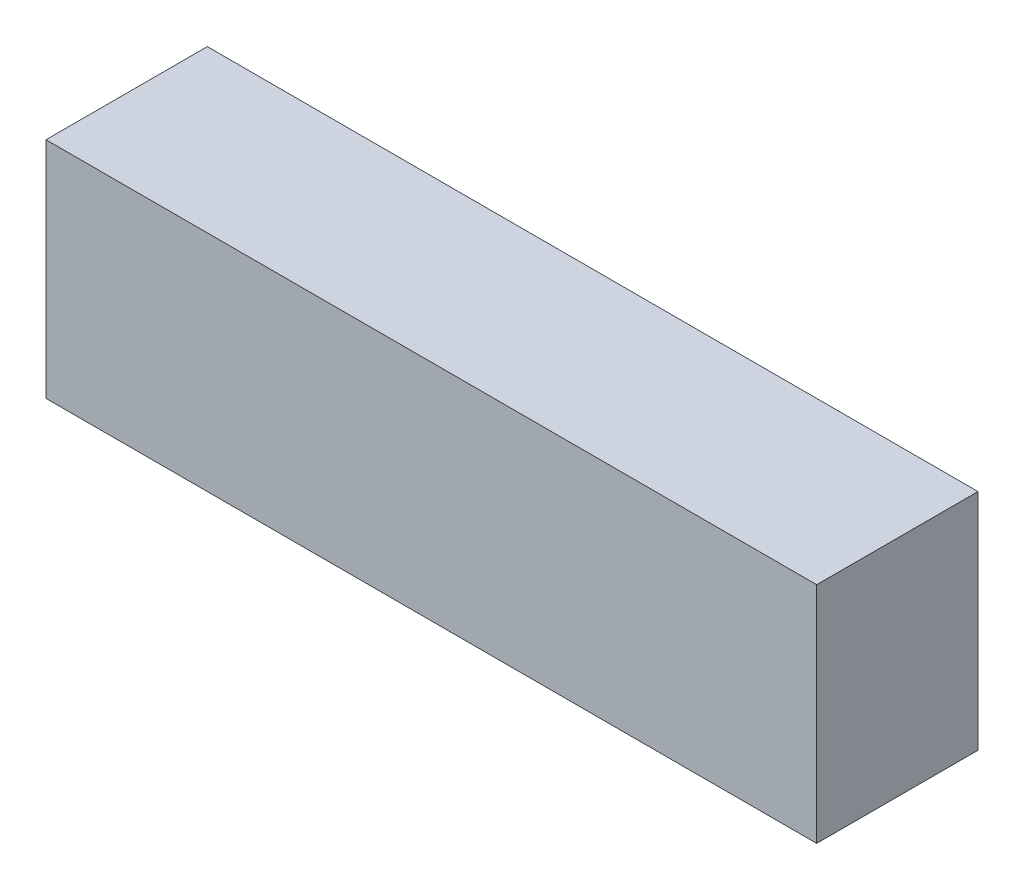
from build123d import *

# Parameters (mm, degrees)
SKETCH1_W           = 43
SKETCH1_H           = 12.5
BOSS_EXTRUDE1_DEPTH = 9


with BuildPart() as part:
    # Sketch1 → Boss-Extrude1 (new body)
    with BuildSketch(Plane(origin=(169.49387324, 0, 0), x_dir=(1, 0, 0), z_dir=(0, 0, 1))):
        with Locations((-169.49387324, 0)):
            Rectangle(SKETCH1_W, SKETCH1_H)
    extrude(amount=BOSS_EXTRUDE1_DEPTH)


solid = part.part
